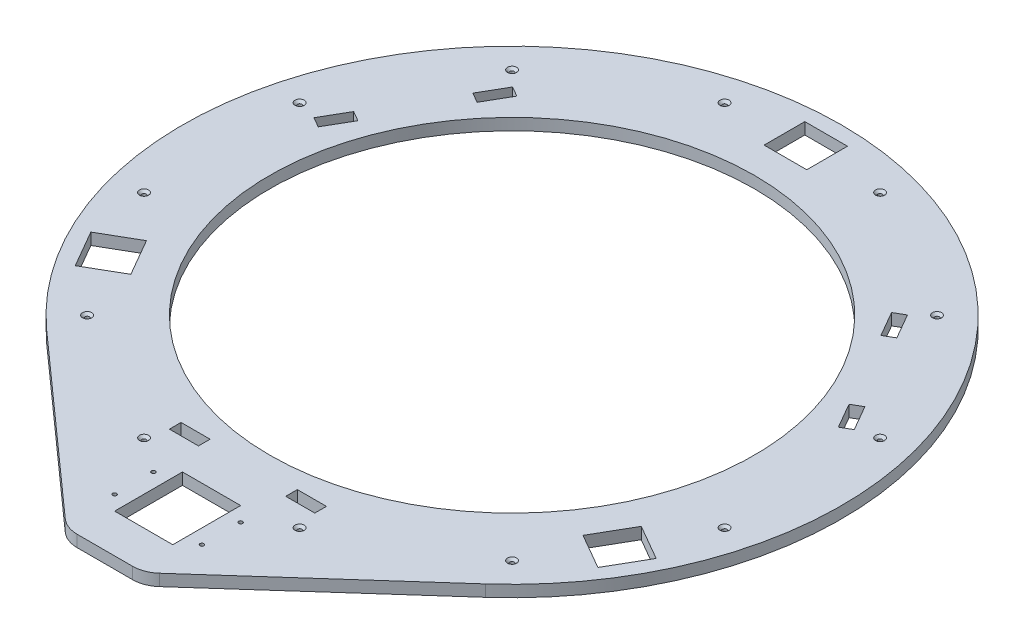
from build123d import *

# Parameters (mm, degrees)
SKETCH1_R                                      = 340
SKETCH1_R_2                                    = 250
BOSS_EXTRUDE1_DEPTH                            = 12
SKETCH7_W                                      = 30
SKETCH7_H                                      = 12
CUT_EXTRUDE2_DEPTH                             = 12
CIRPATTERN3_COUNT                              = 3
BOSS_EXTRUDE3_DEPTH                            = 12
SKETCH9_W                                      = 60
SKETCH9_H                                      = 70
CUT_EXTRUDE3_DEPTH                             = 12
CUT_EXTRUDE4_DEPTH                             = 12
CIRPATTERN4_COUNT                              = 3
SKETCH11_R                                     = 2
CUT_EXTRUDE5_DEPTH                             = 12
FILLET1_R                                      = 30
CSK_FOR_M4_FLAT_HEAD_MACHINE_SCREW_D           = 4.5
CSK_FOR_M4_FLAT_HEAD_MACHINE_SCREW_CSINK_D     = 9.4
CSK_FOR_M4_FLAT_HEAD_MACHINE_SCREW_CSINK_ANGLE = 90


with BuildPart() as part:
    # Sketch1 → Boss-Extrude1 (new body)
    with BuildSketch(Plane(origin=(0, 82.464823413, 0), x_dir=(1, 0, 0), z_dir=(0, 1, 0))):
        Circle(SKETCH1_R)
        Circle(SKETCH1_R_2, mode=Mode.SUBTRACT)
    extrude(amount=-BOSS_EXTRUDE1_DEPTH)

    # Sketch7 → Cut-Extrude2 (cut)
    with BuildSketch(Plane.XZ.offset(-70.464823413)):
        with Locations((60, 272.5)):
            Rectangle(SKETCH7_W, SKETCH7_H)
        with Locations((-60, 272.5)):
            Rectangle(SKETCH7_W, SKETCH7_H)
    cut_extrude2 = extrude(amount=-CUT_EXTRUDE2_DEPTH, mode=Mode.SUBTRACT)

    # CirPattern3: Cut-Extrude2 ×3 about axis
    cirpattern3_axis = Axis((0, 0, 0), (0, 1, 0))
    for i in range(1, CIRPATTERN3_COUNT):
        add(cut_extrude2.rotate(cirpattern3_axis, i * 360 / CIRPATTERN3_COUNT), mode=Mode.SUBTRACT)

    # Sketch8 → Boss-Extrude3 (add)
    with BuildSketch(Plane(origin=(0, 82.464823413, 0), x_dir=(1, 0, 0), z_dir=(0, 1, 0))):
        with BuildLine():
            Line((-40, -420), (40, -420))
            Line((40, -420), (226.378812173, -253.678208364))
            ThreePointArc((226.378812173, -253.678208364), (0, -340), (-226.378812173, -253.678208364))
            Line((-226.378812173, -253.678208364), (-40, -420))
        make_face()
    extrude(amount=-BOSS_EXTRUDE3_DEPTH)

    # Sketch9 → Cut-Extrude3 (cut)
    with BuildSketch(Plane(origin=(0, 82.464823413, 0), x_dir=(1, 0, 0), z_dir=(0, 1, 0))):
        with Locations((0, -345)):
            Rectangle(SKETCH9_W, SKETCH9_H)
    extrude(amount=-CUT_EXTRUDE3_DEPTH, mode=Mode.SUBTRACT)

    # Sketch10 → Cut-Extrude4 (cut)
    with BuildSketch(Plane(origin=(0, 82.464823413, 0), x_dir=(1, 0, 0), z_dir=(0, 1, 0))):
        Polygon((233.219163867, -160.052558883), (255.219163867, -121.947441117), (291.592230826, -142.947441117), (269.592230826, -181.052558883), align=None)
    cut_extrude4 = extrude(amount=-CUT_EXTRUDE4_DEPTH, mode=Mode.SUBTRACT)

    # CirPattern4: Cut-Extrude4 ×3 about axis
    cirpattern4_axis = Axis((0, 0, 0), (0, 1, 0))
    for i in range(1, CIRPATTERN4_COUNT):
        add(cut_extrude4.rotate(cirpattern4_axis, i * 360 / CIRPATTERN4_COUNT), mode=Mode.SUBTRACT)

    # Sketch11 → Cut-Extrude5 (cut)
    with BuildSketch(Plane(origin=(0, 82.464823413, 0), x_dir=(1, 0, 0), z_dir=(0, 1, 0))):
        with Locations((-45, -365)):
            Circle(SKETCH11_R)
        with Locations((-45, -325)):
            Circle(SKETCH11_R)
        with Locations((45, -365)):
            Circle(SKETCH11_R)
        with Locations((45, -325)):
            Circle(SKETCH11_R)
    extrude(amount=-CUT_EXTRUDE5_DEPTH, mode=Mode.SUBTRACT)

    # Fillet1
    fillet1_edges = [part.edges().sort_by_distance(p)[0] for p in [
        (-40, 76.464823413, 420),
        (40, 76.464823413, 420),
    ]]
    fillet(fillet1_edges, radius=FILLET1_R)

    # CSK for M4 Flat Head Machine Screw (through all)
    with Locations(Plane(origin=(0, 82.464823413, 0), x_dir=(1, 0, 0), z_dir=(0, 1, 0))):
        with Locations((80.233903982, 299.43700615), (219.203102168, 219.203102168), (299.43700615, 80.233903982), (299.43700615, -80.233903982), (219.203102168, -219.203102168), (80.233903982, -299.43700615), (-80.233903982, -299.43700615), (-219.203102168, -219.203102168), (-299.43700615, -80.233903982), (-299.43700615, 80.233903982), (-219.203102168, 219.203102168), (-80.233903982, 299.43700615), (0, 0)):
            CounterSinkHole(CSK_FOR_M4_FLAT_HEAD_MACHINE_SCREW_D / 2, CSK_FOR_M4_FLAT_HEAD_MACHINE_SCREW_CSINK_D / 2, counter_sink_angle=CSK_FOR_M4_FLAT_HEAD_MACHINE_SCREW_CSINK_ANGLE)


solid = part.part
